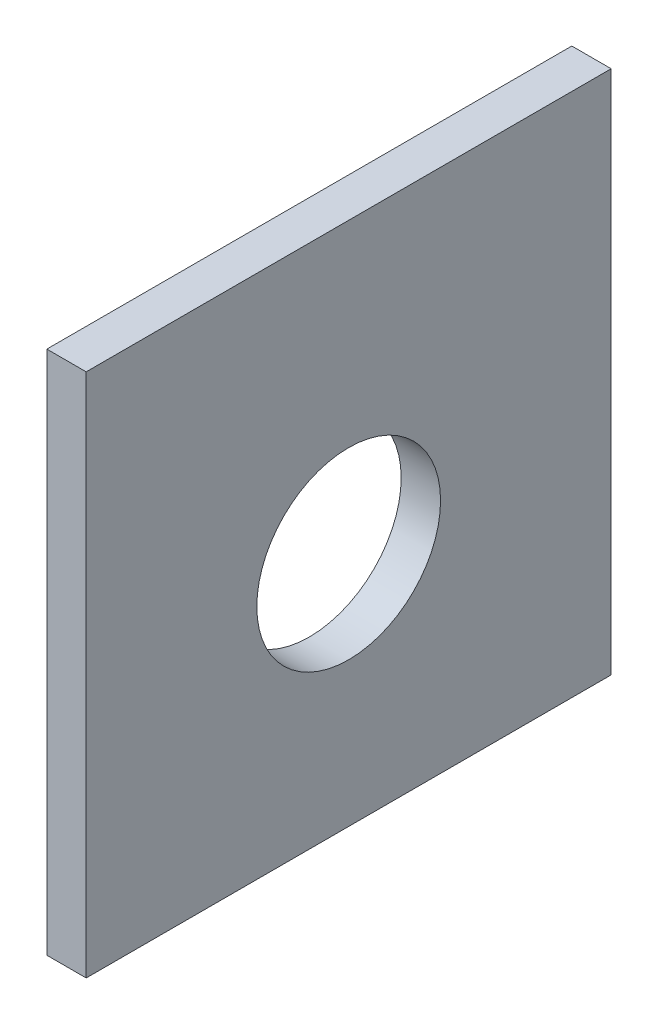
from build123d import *

# Parameters (mm, degrees)
CROQUIS1_W              = 40
CROQUIS1_H              = 40
CROQUIS1_R              = 7
SALIENTE_EXTRUIR1_DEPTH = 3


with BuildPart() as part:
    # Croquis1 → Saliente-Extruir1 (new body)
    with BuildSketch(Plane(origin=(0, 0, 0), x_dir=(0, 0, -1), z_dir=(1, 0, 0))):
        with Locations((-11.269245759, -12.197301292)):
            Rectangle(CROQUIS1_W, CROQUIS1_H)
        with Locations((-11.269245759, -14.197301292)):
            Circle(CROQUIS1_R, mode=Mode.SUBTRACT)
    extrude(amount=SALIENTE_EXTRUIR1_DEPTH)


solid = part.part
